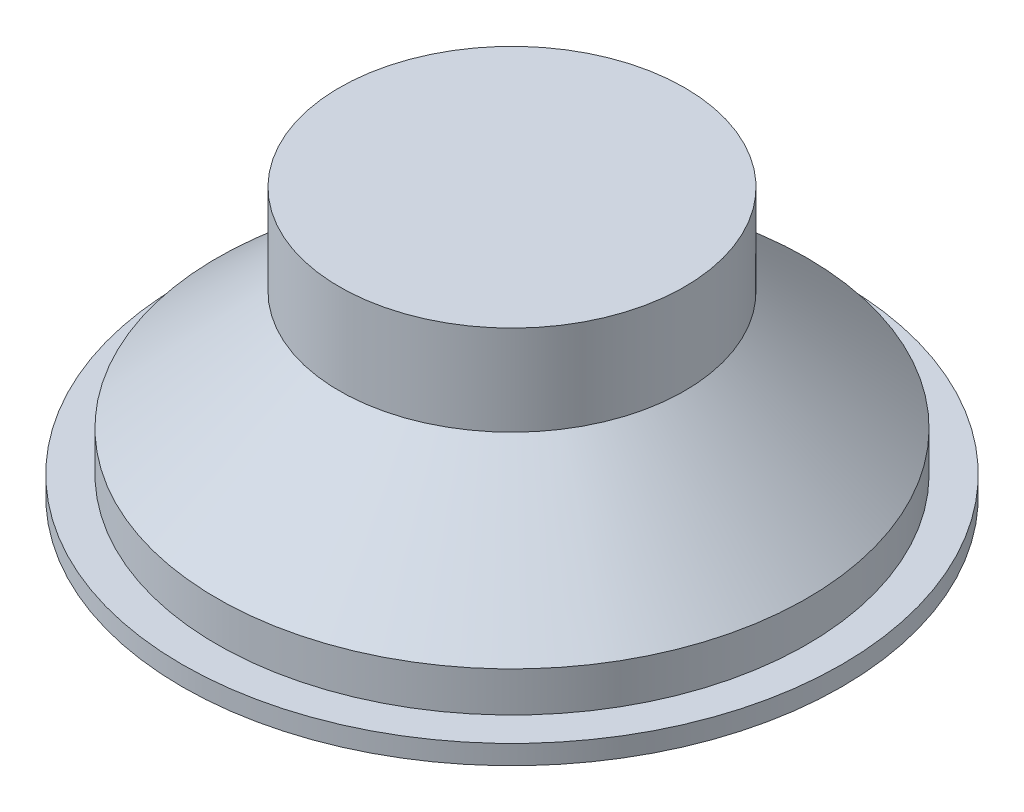
from build123d import *


with BuildPart() as part:
    # Эскиз1 → Повернуть1 (revolve)
    with BuildSketch(Plane(origin=(0, 0, 0), x_dir=(0, 0, -1), z_dir=(1, 0, 0))):
        Polygon((0, 104), (0, 50), (-30, 50), (-107.5, 0), (-128, 0), (-128, 7.5), (-114.5, 7.5), (-114.5, 23), (-62, 69), (-67, 69), (-67, 104), align=None)
    revolve(axis=Axis((0, 0, 0), (0, 1, 0)))


solid = part.part
